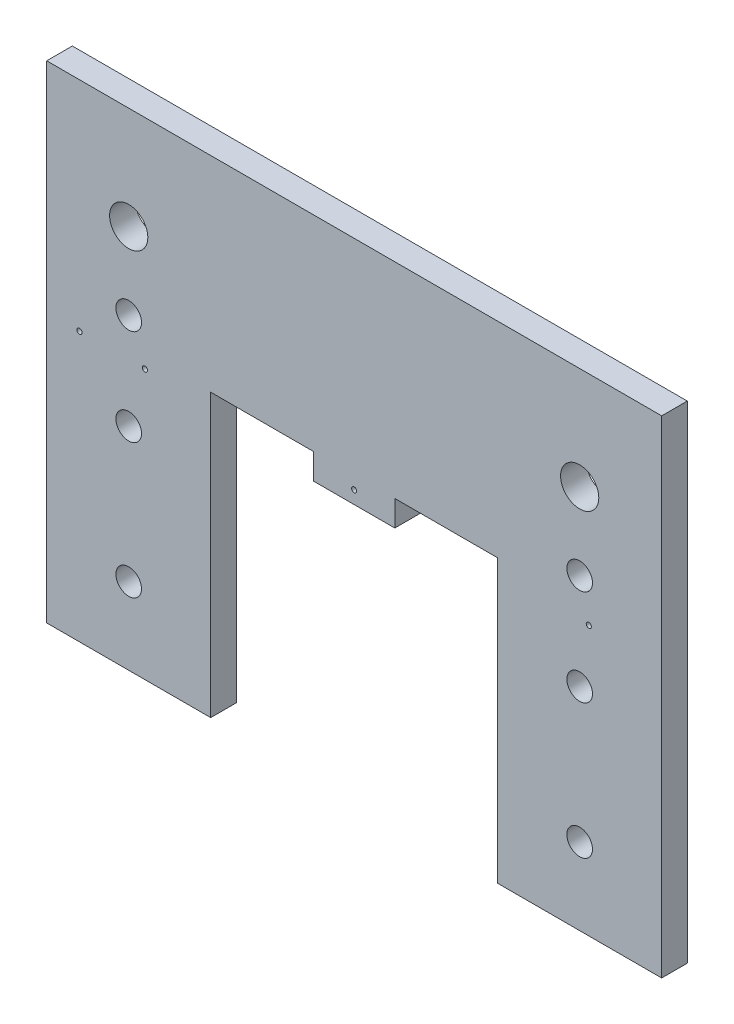
from build123d import *

# Parameters (mm, degrees)
SKETCH1_R           = 4.7371
SKETCH1_R_2         = 3.175
BOSS_EXTRUDE1_DEPTH = 6.35
SKETCH2_W           = 25.498289586
SKETCH2_H           = 6.35
CUT_EXTRUDE1_DEPTH  = 6.35
SKETCH3_R           = 0.635
CUT_EXTRUDE2_DEPTH  = 6.35


with BuildPart() as part:
    # Sketch1 → Boss-Extrude1 (new body)
    with BuildSketch(Plane.XY):
        Polygon((0, 0), (40.64, 0), (40.64, 63.5), (111.76, 63.5), (111.76, 0), (152.4, 0), (152.4, 69.85), (152.4, 120.65), (111.76, 120.65), (40.64, 120.65), (0, 120.65), (0, 69.85), align=None)
        with Locations((20.32, 95.25)):
            Circle(SKETCH1_R, mode=Mode.SUBTRACT)
        with Locations((132.08, 95.25)):
            Circle(SKETCH1_R, mode=Mode.SUBTRACT)
        with Locations((132.08, 76.2)):
            Circle(SKETCH1_R_2, mode=Mode.SUBTRACT)
        with Locations((20.32, 76.2)):
            Circle(SKETCH1_R_2, mode=Mode.SUBTRACT)
        with Locations((20.32, 52.3875)):
            Circle(SKETCH1_R_2, mode=Mode.SUBTRACT)
        with Locations((132.08, 52.3875)):
            Circle(SKETCH1_R_2, mode=Mode.SUBTRACT)
        with Locations((20.32, 19.05)):
            Circle(SKETCH1_R_2, mode=Mode.SUBTRACT)
        with Locations((132.08, 19.05)):
            Circle(SKETCH1_R_2, mode=Mode.SUBTRACT)
    extrude(amount=BOSS_EXTRUDE1_DEPTH)

    # Sketch2 → Cut-Extrude1 (cut)
    with BuildSketch(Plane(origin=(0, 0, 0), x_dir=(-1, 0, 0), z_dir=(0, 0, -1))):
        with Locations((-99.010855207, 66.675)):
            Rectangle(SKETCH2_W, SKETCH2_H)
        with Locations((-53.389144793, 66.675)):
            Rectangle(SKETCH2_W, SKETCH2_H)
    extrude(amount=-CUT_EXTRUDE1_DEPTH, mode=Mode.SUBTRACT)

    # Sketch3 → Cut-Extrude2 (cut)
    with BuildSketch(Plane(origin=(0, 0, 0), x_dir=(-1, 0, 0), z_dir=(0, 0, -1))):
        with Locations((-134.339930145, 66.675)):
            Circle(SKETCH3_R)
        with Locations((-98.219790435, 66.675)):
            Circle(SKETCH3_R)
        with Locations((-24.342185699, 66.675)):
            Circle(SKETCH3_R)
        with Locations((-76.2, 66.675)):
            Circle(SKETCH3_R)
        with Locations((-8.1140619, 66.675)):
            Circle(SKETCH3_R)
    extrude(amount=-CUT_EXTRUDE2_DEPTH, mode=Mode.SUBTRACT)


solid = part.part
